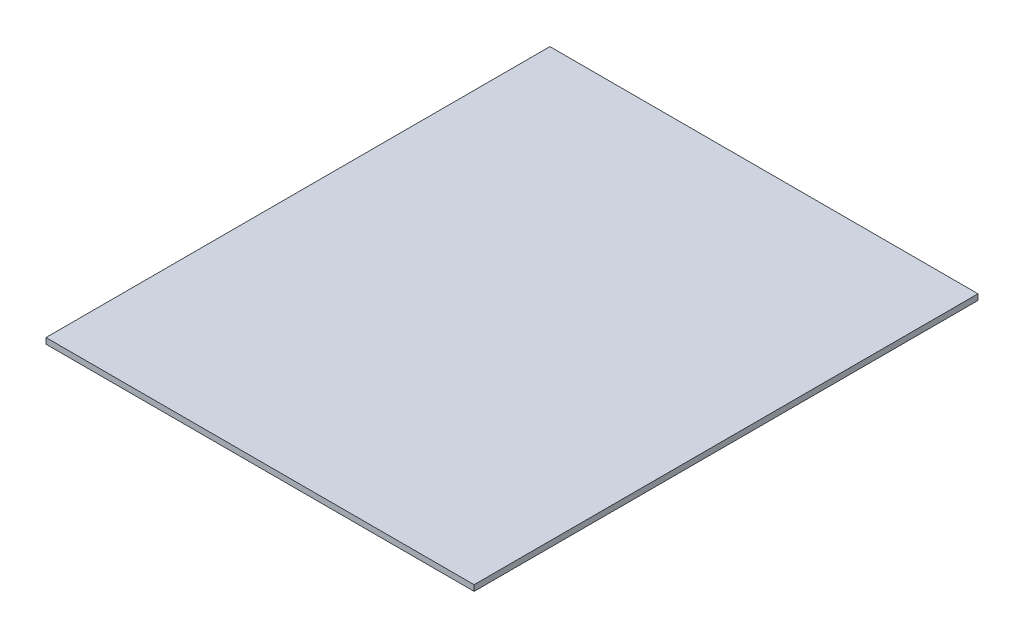
from build123d import *

# Parameters (mm, degrees)
SKETCH2_W           = 221
SKETCH2_H           = 260.124897979
BOSS_EXTRUDE1_DEPTH = 3


with BuildPart() as part:
    # Sketch2 → Boss-Extrude1 (new body)
    with BuildSketch(Plane(origin=(0, 330, 0), x_dir=(1, 0, 0), z_dir=(0, 1, 0))):
        with Locations((0, -4.562448989)):
            Rectangle(SKETCH2_W, SKETCH2_H)
    extrude(amount=BOSS_EXTRUDE1_DEPTH)


solid = part.part
